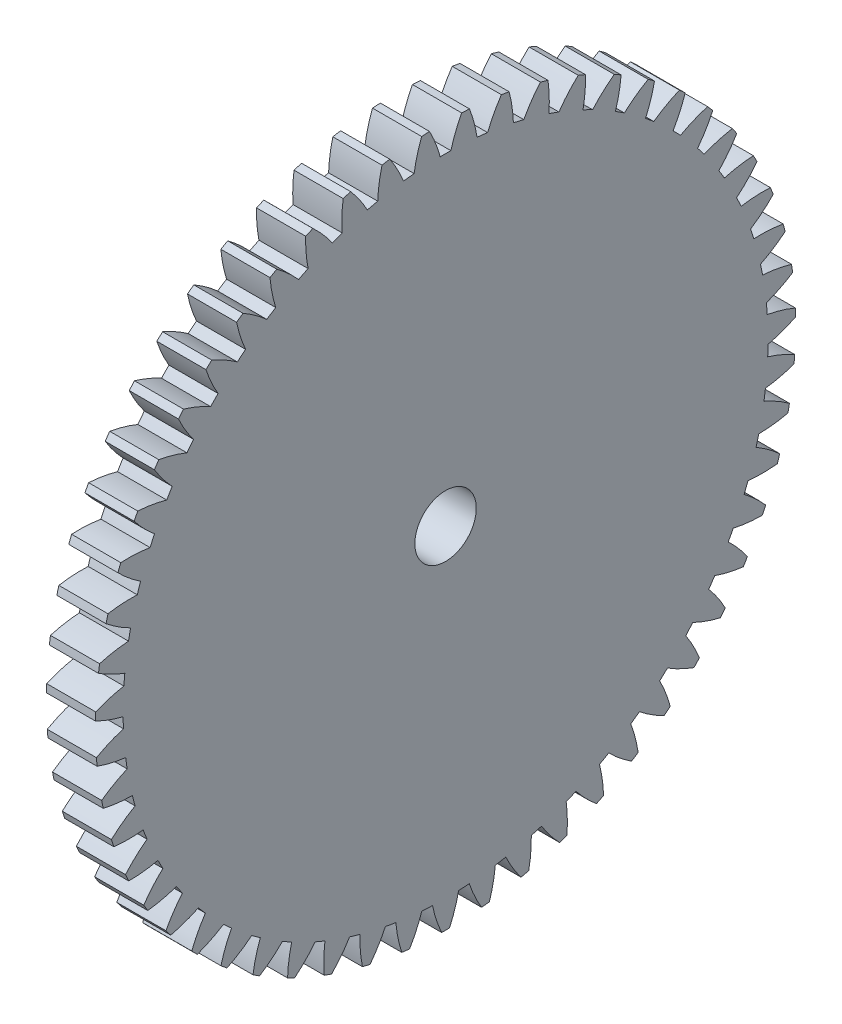
from build123d import *

# Parameters (mm, degrees)
BASPROSKE_W     = 4
BASPROSKE_H     = 28.5
TOOTHCUT_DEPTH  = 41.503086302
TEETHCUTS_COUNT = 55
TEETHCUTS_ANGLE = 353.454545455
BORSKE_R        = 2.5
BORE_DEPTH      = 50.0000508


with BuildPart() as part:
    # BasProSke → Base-Revolve (revolve)
    with BuildSketch(Plane(origin=(0, 0, 0), x_dir=(1, 0, 0), z_dir=(0, 1, 0)), mode=Mode.PRIVATE) as base_revolve_sk:
        with Locations((2, 14.25)):
            Rectangle(BASPROSKE_W, BASPROSKE_H)
    revolve(base_revolve_sk.sketch.rotate(Axis((-10, 0, 0), (1, 0, 0)), 180), axis=Axis((-10, 0, 0), (1, 0, 0)))

    # TooCutSke → ToothCut (cut, through all)
    with BuildSketch(Plane(origin=(0, 0, 0), x_dir=(0, 0, -1), z_dir=(1, 0, 0))):
        with BuildLine():
            ThreePointArc((0.433583944, 26.245418761), (0, 26.249), (-0.433583944, 26.245418761))
            ThreePointArc((-0.433583944, 26.245418761), (-0.814942664, 27.394560811), (-1.320285506, 28.494829204))
            ThreePointArc((-1.320285506, 28.494829204), (0, 28.5254), (1.320285506, 28.494829204))
            ThreePointArc((1.320285506, 28.494829204), (0.814942664, 27.394560811), (0.433583944, 26.245418761))
        make_face()
    toothcut = extrude(amount=TOOTHCUT_DEPTH, mode=Mode.SUBTRACT)

    # TeethCuts: ToothCut ×55 about axis
    teethcuts_axis = Axis((-10, 0, 0), (1, 0, 0))
    for i in range(1, TEETHCUTS_COUNT):
        add(toothcut.rotate(teethcuts_axis, i * TEETHCUTS_ANGLE / (TEETHCUTS_COUNT - 1)), mode=Mode.SUBTRACT)

    # BorSke → Bore (cut, symmetric)
    with BuildSketch(Plane(origin=(0, 0, 0), x_dir=(0, 0, -1), z_dir=(1, 0, 0))):
        with Locations(Location((0, 0, 0), (0, 0, 180))):
            Circle(BORSKE_R)
    extrude(amount=BORE_DEPTH, both=True, mode=Mode.SUBTRACT)


solid = part.part
